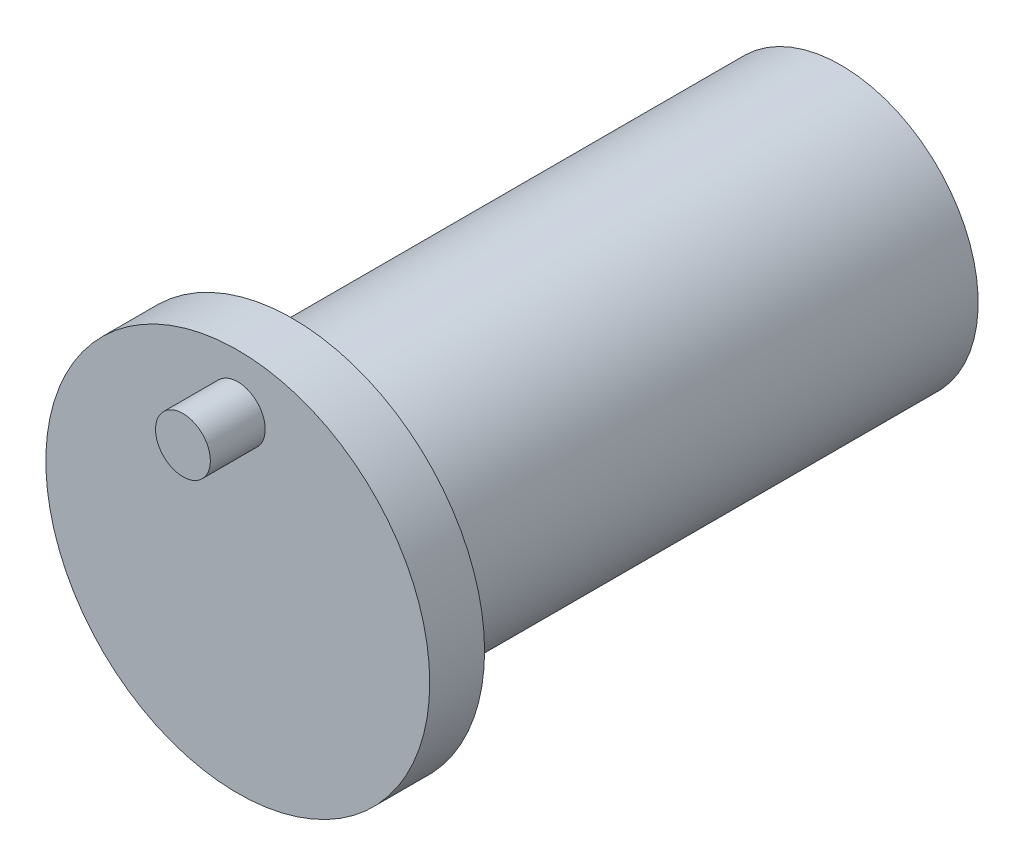
from build123d import *

# Parameters (mm, degrees)
SKETCH1_R           = 7
BOSS_EXTRUDE1_DEPTH = 2
SKETCH2_R           = 1
BOSS_EXTRUDE2_DEPTH = 2
SKETCH3_R           = 5
BOSS_EXTRUDE3_DEPTH = 20


with BuildPart() as part:
    # Sketch1 → Boss-Extrude1 (new body)
    with BuildSketch(Plane.XY):
        Circle(SKETCH1_R)
    extrude(amount=-BOSS_EXTRUDE1_DEPTH)

    # Sketch2 → Boss-Extrude2 (add)
    with BuildSketch(Plane.XY):
        with Locations((0, 5)):
            Circle(SKETCH2_R)
    extrude(amount=BOSS_EXTRUDE2_DEPTH)

    # Sketch3 → Boss-Extrude3 (add)
    with BuildSketch(Plane(origin=(0, 0, -2), x_dir=(-1, 0, 0), z_dir=(0, 0, -1))):
        Circle(SKETCH3_R)
    extrude(amount=BOSS_EXTRUDE3_DEPTH)


solid = part.part
